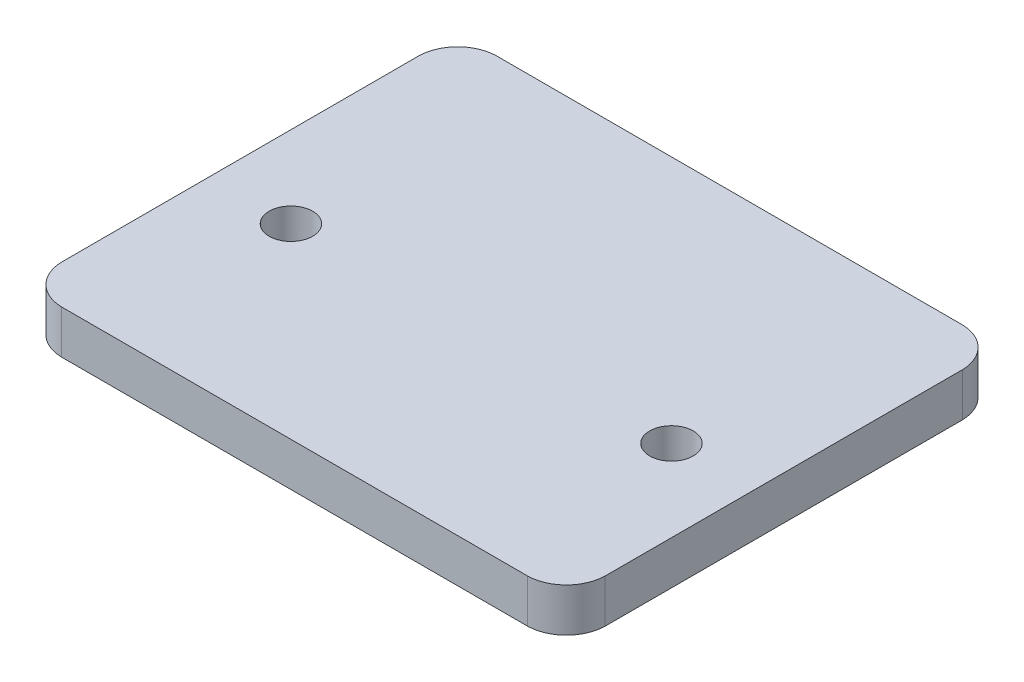
from build123d import *

# Parameters (mm, degrees)
SKETCH1_R           = 2
BOSS_EXTRUDE2_DEPTH = 4
SKETCH1_8_R         = 4.5
CUT_EXTRUDE4_DEPTH  = 2


with BuildPart() as part:
    # Sketch1 → Boss-Extrude2 (new body)
    with BuildSketch(Plane(origin=(0, 0, 0), x_dir=(1, 0, 0), z_dir=(0, 1, 0))):
        with BuildLine():
            Line((21.446973136, 20), (-21.446973136, 20))
            ThreePointArc((-21.446973136, 20), (-23.935145745, 18.935145745), (-25, 16.446973136))
            Line((-25, 16.446973136), (-25, -16.446973136))
            ThreePointArc((-25, -16.446973136), (-23.935145745, -18.935145745), (-21.446973136, -20))
            Line((-21.446973136, -20), (21.446973136, -20))
            ThreePointArc((21.446973136, -20), (23.935145745, -18.935145745), (25, -16.446973136))
            Line((25, -16.446973136), (25, 16.446973136))
            ThreePointArc((25, 16.446973136), (23.935145745, 18.935145745), (21.446973136, 20))
        make_face()
        with Locations((-17.507214432, -2.825963154)):
            Circle(SKETCH1_R, mode=Mode.SUBTRACT)
        with Locations((17.492785568, -2.825963154)):
            Circle(SKETCH1_R, mode=Mode.SUBTRACT)
    extrude(amount=BOSS_EXTRUDE2_DEPTH)

    # Sketch1_8 → Cut-Extrude4 (cut)
    with BuildSketch(Plane(origin=(0, 0, 0), x_dir=(1, 0, 0), z_dir=(0, 1, 0))):
        with Locations((0, 5.276580282)):
            Circle(SKETCH1_8_R)
    extrude(amount=CUT_EXTRUDE4_DEPTH, mode=Mode.SUBTRACT)


solid = part.part
